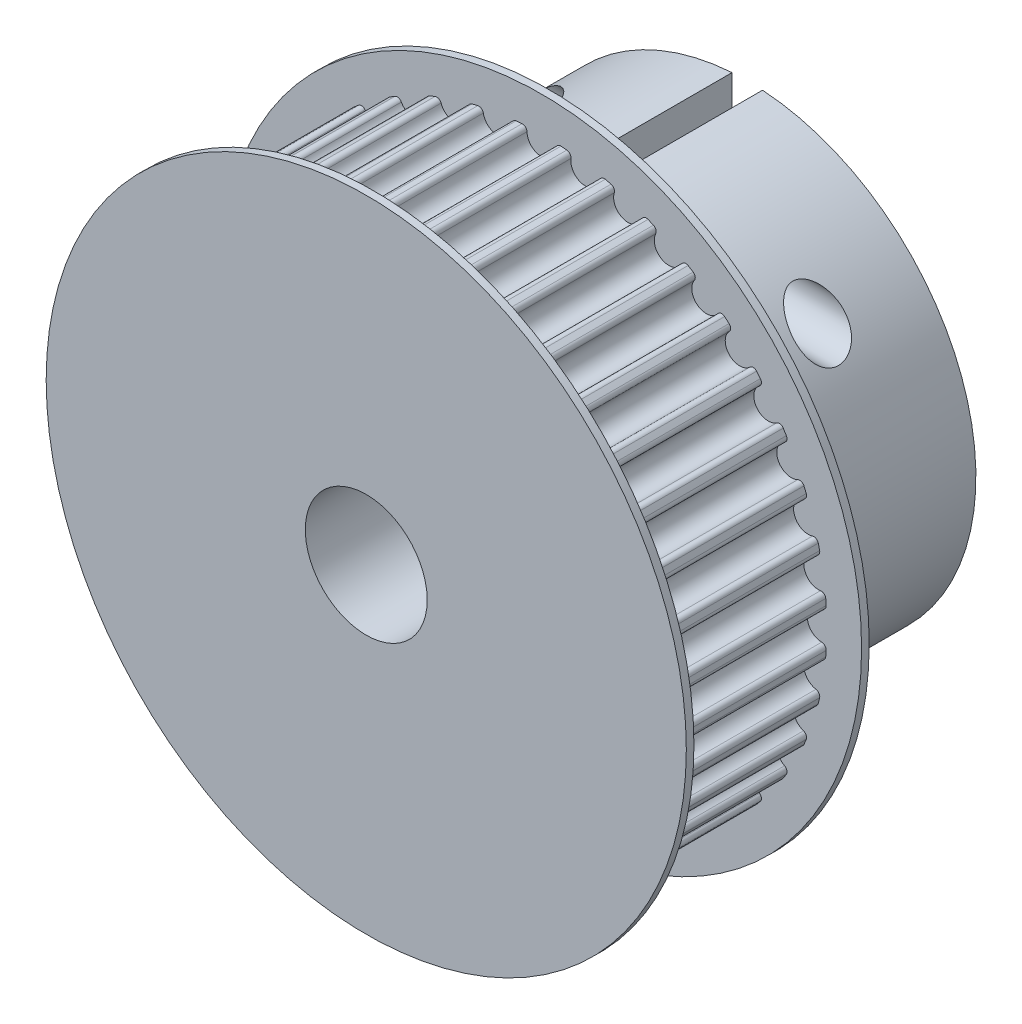
from build123d import *

# Parameters (mm, degrees)
SKETCH_1_R               = 18.72
EXTRUDE_1_DEPTH          = 11
CUT_EXTRUDE_1_DEPTH      = 11
PATTERN_CIRCULAR_1_COUNT = 40
SKETCH_4_R               = 21
EXTRUDE_2_DEPTH          = 0.5
SKETCH_5_R               = 21
EXTRUDE_3_DEPTH          = 0.5
SKETCH_6_R               = 15
EXTRUDE_4_DEPTH          = 13
CUT_EXTRUDE_2_REACH      = 27
SKETCH_7_R               = 4
SKETCH_8_W               = 2
SKETCH_8_H               = 11.127016654
CUT_EXTRUDE_3_DEPTH      = 12.5
CUT_EXTRUDE_4_DEPTH      = 1
SKETCH_10_R              = 1.65
CUT_EXTRUDE_5_DEPTH      = 22
CUT_EXTRUDE_5_DEPTH_BACK = 22
CUT_EXTRUDE_START        = -5
SKETCH_11_R              = 3.6
CUT_EXTRUDE_6_DEPTH      = 17


with BuildPart() as part:
    # 草圖1 → 填料-伸長1 (new body)
    with BuildSketch(Plane.XY):
        Circle(SKETCH_1_R)
    extrude(amount=EXTRUDE_1_DEPTH)

    # 草圖3 → 除料-伸長1 (cut)
    with BuildSketch(Plane.XY.offset(11)):
        with BuildLine():
            ThreePointArc((-1.275408738, 18.67650215), (0, 18.72), (1.275408738, 18.67650215))
            ThreePointArc((1.275408738, 18.67650215), (1.051759729, 18.597893115), (0.955, 18.381477278))
            ThreePointArc((0.955, 18.381477278), (0, 17.44), (-0.955, 18.381477278))
            ThreePointArc((-0.955, 18.381477278), (-1.051759729, 18.597893115), (-1.275408738, 18.67650215))
        make_face()
    cut_extrude_1 = extrude(amount=-CUT_EXTRUDE_1_DEPTH, mode=Mode.SUBTRACT)

    # 環狀複製排列1: 除料-伸長1 ×40 about axis
    pattern_circular_1_axis = Axis((0, 0, 0), (0, 0, 1))
    for i in range(1, PATTERN_CIRCULAR_1_COUNT):
        add(cut_extrude_1.rotate(pattern_circular_1_axis, i * 360 / PATTERN_CIRCULAR_1_COUNT), mode=Mode.SUBTRACT)

    # 草圖4 → 填料-伸長2 (add)
    with BuildSketch(Plane.XY.offset(11)):
        Circle(SKETCH_4_R)
    extrude(amount=EXTRUDE_2_DEPTH)

    # 草圖5 → 填料-伸長3 (add)
    with BuildSketch(Plane(origin=(0, 0, 0), x_dir=(-1, 0, 0), z_dir=(0, 0, -1))):
        Circle(SKETCH_5_R)
    extrude(amount=EXTRUDE_3_DEPTH)

    # 草圖6 → 填料-伸長4 (add)
    with BuildSketch(Plane(origin=(0, 0, -0.5), x_dir=(-1, 0, 0), z_dir=(0, 0, -1))):
        Circle(SKETCH_6_R)
    extrude(amount=EXTRUDE_4_DEPTH)

    # 草圖7 → 除料-伸長2 (cut, up to next)
    with BuildSketch(Plane(origin=(0, 0, -13.5), x_dir=(-1, 0, 0), z_dir=(0, 0, -1)), mode=Mode.PRIVATE) as cut_extrude_2_sk1:
        Circle(SKETCH_7_R)
    cut_extrude_2_tool1 = extrude(cut_extrude_2_sk1.sketch, amount=-CUT_EXTRUDE_2_REACH, mode=Mode.PRIVATE) & part.part
    add(cut_extrude_2_tool1.solids().sort_by_distance((0, 0, -13.5))[0], mode=Mode.SUBTRACT)

    # 草圖8 → 除料-伸長3 (cut)
    with BuildSketch(Plane(origin=(0, 0, -13.5), x_dir=(-1, 0, 0), z_dir=(0, 0, -1))):
        with Locations((0, 9.436491673)):
            Rectangle(SKETCH_8_W, SKETCH_8_H)
    extrude(amount=-CUT_EXTRUDE_3_DEPTH, mode=Mode.SUBTRACT)

    # 草圖9 → 除料-伸長4 (cut, symmetric)
    with BuildSketch(Plane(origin=(0, 0, 0), x_dir=(0, 0, -1), z_dir=(1, 0, 0))):
        Polygon((13.5, -2.5), (13.5, -10.5), (6.5, -2.5), align=None)
    extrude(amount=CUT_EXTRUDE_4_DEPTH, both=True, mode=Mode.SUBTRACT)

    # 草圖10 → 除料-伸長5 (cut, two sides)
    with BuildSketch(Plane(origin=(0, 0, 0), x_dir=(0, 0, -1), z_dir=(1, 0, 0))) as cut_extrude_5_sk:
        with Locations((7, 9.966629547)):
            Circle(SKETCH_10_R)
    extrude(amount=CUT_EXTRUDE_5_DEPTH, mode=Mode.SUBTRACT)
    extrude(cut_extrude_5_sk.sketch, amount=-CUT_EXTRUDE_5_DEPTH_BACK, mode=Mode.SUBTRACT)

    # 草圖11 → 除料-伸長6 (cut, through all)
    with BuildSketch(Plane(origin=(0, 0, 0), x_dir=(0, 0, -1), z_dir=(1, 0, 0)).offset(CUT_EXTRUDE_START)):
        with Locations((7, 9.966629547)):
            Circle(SKETCH_11_R)
    extrude(amount=-CUT_EXTRUDE_6_DEPTH, mode=Mode.SUBTRACT)


solid = part.part
